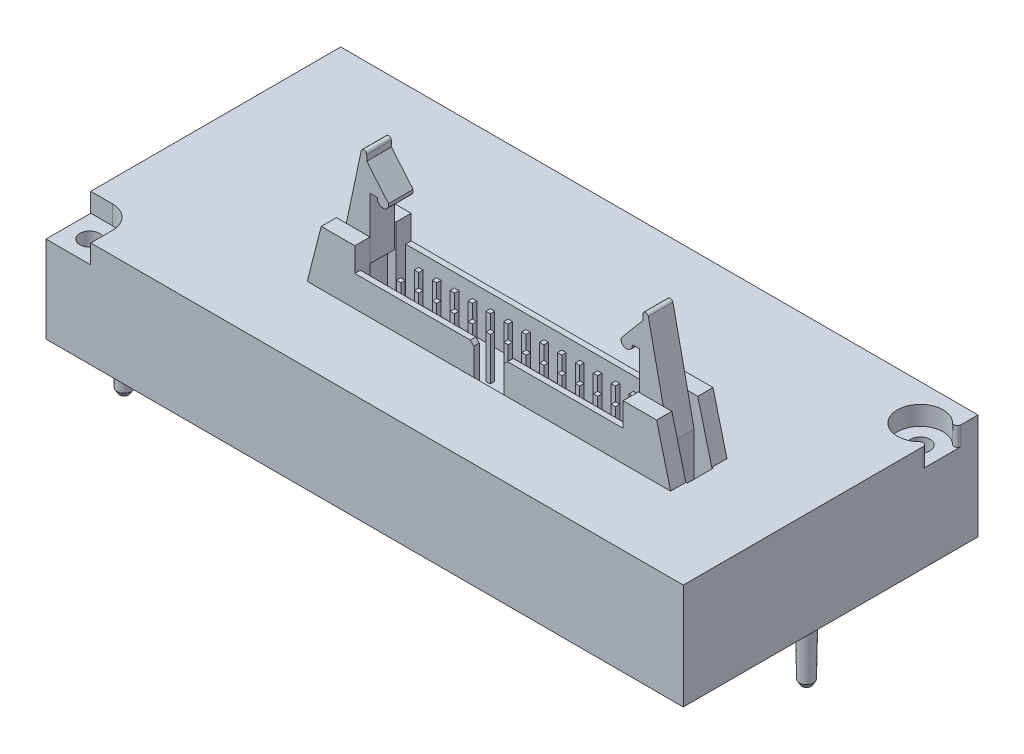
from build123d import *

# Parameters (mm, degrees)
SKETCH1_W                = 90.5
SKETCH1_H                = 41.85
SKETCH1_R                = 1.4
BOSS_EXTRUDE1_DEPTH      = 15
SKETCH2_W                = 105
SKETCH2_H                = 60
CUT_EXTRUDE1_DEPTH       = 2.7
BOSS_EXTRUDE2_DEPTH      = 4
BOSS_EXTRUDE2_DEPTH_BACK = 4
SKETCH7_W                = 38.1
SKETCH7_H                = 6.43
CUT_EXTRUDE2_DEPTH       = 6.4
CUT_EXTRUDE2_DEPTH_BACK  = 6.4
CUT_EXTRUDE3_DEPTH       = 1
SKETCH9_W                = 3.68
SKETCH9_H                = 13
CUT_EXTRUDE4_DEPTH       = 7
SKETCH10_W               = 3.68
SKETCH10_H               = 13
CUT_EXTRUDE5_DEPTH       = 7
SKETCH11_R               = 0.5
BOSS_EXTRUDE3_DEPTH      = 3
BOSS_EXTRUDE3_DEPTH_BACK = 3
SKETCH12_R               = 0.5
BOSS_EXTRUDE4_DEPTH      = 3
BOSS_EXTRUDE4_DEPTH_BACK = 3
BOSS_EXTRUDE5_DEPTH      = 1.75
BOSS_EXTRUDE5_DEPTH_BACK = 1.75
BOSS_EXTRUDE6_DEPTH      = 1.75
BOSS_EXTRUDE6_DEPTH_BACK = 1.75
SKETCH15_W               = 0.62
SKETCH15_H               = 0.62
BOSS_EXTRUDE7_DEPTH      = 6.1
SKETCH16_W               = 0.62
SKETCH16_H               = 0.62
BOSS_EXTRUDE8_DEPTH      = 6.1
SKETCH17_W               = 0.62
SKETCH17_H               = 0.62
BOSS_EXTRUDE9_DEPTH      = 6.1
SKETCH18_W               = 0.62
SKETCH18_H               = 0.62
BOSS_EXTRUDE10_DEPTH     = 6.1
SKETCH19_W               = 0.62
SKETCH19_H               = 0.62
BOSS_EXTRUDE11_DEPTH     = 6.1
SKETCH20_W               = 0.62
SKETCH20_H               = 0.62
BOSS_EXTRUDE12_DEPTH     = 6.1
SKETCH21_W               = 0.62
SKETCH21_H               = 0.62
BOSS_EXTRUDE13_DEPTH     = 6.1
SKETCH22_W               = 0.62
SKETCH22_H               = 0.62
BOSS_EXTRUDE14_DEPTH     = 6.1
SKETCH23_W               = 0.62
SKETCH23_H               = 0.62
BOSS_EXTRUDE15_DEPTH     = 6.1
SKETCH24_W               = 0.62
SKETCH24_H               = 0.62
BOSS_EXTRUDE16_DEPTH     = 6.1
SKETCH25_W               = 0.62
SKETCH25_H               = 0.62
BOSS_EXTRUDE17_DEPTH     = 6.1
SKETCH26_W               = 0.62
SKETCH26_H               = 0.62
BOSS_EXTRUDE18_DEPTH     = 6.1
SKETCH27_W               = 0.62
SKETCH27_H               = 0.62
BOSS_EXTRUDE19_DEPTH     = 6.1
SKETCH28_W               = 0.62
SKETCH28_H               = 0.62
BOSS_EXTRUDE20_DEPTH     = 6.1
SKETCH29_W               = 0.62
SKETCH29_H               = 0.62
BOSS_EXTRUDE21_DEPTH     = 6.1
SKETCH30_W               = 0.62
SKETCH30_H               = 0.62
BOSS_EXTRUDE22_DEPTH     = 6.1
SKETCH31_W               = 0.62
SKETCH31_H               = 0.62
BOSS_EXTRUDE23_DEPTH     = 6.1
SKETCH32_W               = 0.62
SKETCH32_H               = 0.62
BOSS_EXTRUDE24_DEPTH     = 6.1
SKETCH33_W               = 0.62
SKETCH33_H               = 0.62
BOSS_EXTRUDE25_DEPTH     = 6.1
SKETCH34_W               = 0.62
SKETCH34_H               = 0.62
BOSS_EXTRUDE26_DEPTH     = 6.1
SKETCH35_W               = 0.62
SKETCH35_H               = 0.62
BOSS_EXTRUDE27_DEPTH     = 6.1
SKETCH36_W               = 0.62
SKETCH36_H               = 0.62
BOSS_EXTRUDE28_DEPTH     = 6.1
SKETCH37_W               = 0.62
SKETCH37_H               = 0.62
BOSS_EXTRUDE29_DEPTH     = 6.1
SKETCH38_W               = 0.62
SKETCH38_H               = 0.62
BOSS_EXTRUDE30_DEPTH     = 6.1
SKETCH39_W               = 0.62
SKETCH39_H               = 0.62
BOSS_EXTRUDE31_DEPTH     = 6.1
SKETCH40_W               = 0.62
SKETCH40_H               = 0.62
BOSS_EXTRUDE32_DEPTH     = 6.1


with BuildPart() as part:
    # Sketch1 → Boss-Extrude1 (new body)
    with BuildSketch(Plane(origin=(0, 0, 0), x_dir=(1, 0, 0), z_dir=(0, 1, 0))):
        with Locations((11, -5.675)):
            Rectangle(SKETCH1_W, SKETCH1_H)
        with Locations((53.15, 10.15)):
            Circle(SKETCH1_R, mode=Mode.SUBTRACT)
        with Locations((-31.15, -23.5)):
            Circle(SKETCH1_R, mode=Mode.SUBTRACT)
    extrude(amount=BOSS_EXTRUDE1_DEPTH)

    # Sketch2 → Cut-Extrude1 (cut)
    with BuildSketch(Plane(origin=(0, 15, 0), x_dir=(1, 0, 0), z_dir=(0, 1, 0))):
        with Locations((12.5, -5)):
            Rectangle(SKETCH2_W, SKETCH2_H)
        with BuildLine():
            Line((-34.25, 15.25), (-34.25, -20.25))
            Line((-34.25, -20.25), (-31.15, -20.25))
            ThreePointArc((-31.15, -20.25), (-28.851902961, -21.201902961), (-27.9, -23.5))
            Line((-27.9, -23.5), (-27.9, -26.6))
            Line((-27.9, -26.6), (56.25, -26.6))
            Line((56.25, -26.6), (56.25, 7.447686177))
            ThreePointArc((56.25, 7.447686177), (55.945788972, 7.907758648), (55.403333286, 7.807994641))
            ThreePointArc((55.403333286, 7.807994641), (49.9, 10.150000033), (55.403333333, 12.492005314))
            ThreePointArc((55.403333333, 12.492005314), (55.945789002, 12.392241365), (56.25, 12.852313823))
            Line((56.25, 12.852313823), (56.25, 15.25))
            Line((56.25, 15.25), (-34.25, 15.25))
        make_face(mode=Mode.SUBTRACT)
    extrude(amount=-CUT_EXTRUDE1_DEPTH, mode=Mode.SUBTRACT)

    # Sketch3 → Revolve1 (revolve)
    with BuildSketch(Plane.XY.offset(6)):
        Polygon((53.15, 0), (54.3, 0), (54.15, -8.4), (53.8, -9), (53.15, -9), align=None)
    revolve(axis=Axis((53.15, -9, 6), (0, 1, 0)))

    # Sketch4 → Revolve2 (revolve)
    with BuildSketch(Plane.XY.offset(-5.25)):
        Polygon((-31.15, 0), (-30, 0), (-30.15, -8.4), (-30.5, -9), (-31.15, -9), align=None)
    revolve(axis=Axis((-31.15, -9, -5.25), (0, 1, 0)))

    # Sketch5 → Revolve3 (revolve)
    with BuildSketch(Plane.XY.offset(18.6)):
        Polygon((-31.15, 0), (-30, 0), (-30.15, -8.4), (-30.5, -9), (-31.15, -9), align=None)
    revolve(axis=Axis((-31.15, -9, 18.6), (0, 1, 0)))

    # Sketch6 → Boss-Extrude2 (add, two sides)
    with BuildSketch(Plane.XY.offset(11.95)) as boss_extrude2_sk:
        Polygon((-8.225, 13.35), (-8.225, 5.35), (44.225, 5.35), (44.225, 13.35), (41.815, 22.75), (37.05, 22.75), (37.05, 19.35), (-1.05, 19.35), (-1.05, 22.75), (-5.815, 22.75), align=None)
    extrude(amount=BOSS_EXTRUDE2_DEPTH)
    extrude(boss_extrude2_sk.sketch, amount=-BOSS_EXTRUDE2_DEPTH_BACK)

    # Sketch7 → Cut-Extrude2 (cut, two sides)
    with BuildSketch(Plane(origin=(0, 19.35, 0), x_dir=(1, 0, 0), z_dir=(0, 1, 0))) as cut_extrude2_sk:
        with Locations((18, -11.95)):
            Rectangle(SKETCH7_W, SKETCH7_H)
    extrude(amount=CUT_EXTRUDE2_DEPTH, mode=Mode.SUBTRACT)
    extrude(cut_extrude2_sk.sketch, amount=-CUT_EXTRUDE2_DEPTH_BACK, mode=Mode.SUBTRACT)

    # Sketch8 → Cut-Extrude3 (cut)
    with BuildSketch(Plane.XY.offset(15.95)):
        Polygon((15.35, 19.35), (15.85, 18.85), (15.85, 13.45), (16.35, 12.95), (19.65, 12.95), (20.15, 13.45), (20.15, 18.85), (20.65, 19.35), align=None)
    extrude(amount=-CUT_EXTRUDE3_DEPTH, mode=Mode.SUBTRACT)

    # Sketch9 → Cut-Extrude4 (cut)
    with BuildSketch(Plane(origin=(37, 0, 0), x_dir=(0, 0, -1), z_dir=(1, 0, 0))):
        with Locations((-11.95, 16.25)):
            Rectangle(SKETCH9_W, SKETCH9_H)
    extrude(amount=CUT_EXTRUDE4_DEPTH, mode=Mode.SUBTRACT)

    # Sketch10 → Cut-Extrude5 (cut)
    with BuildSketch(Plane(origin=(-1.05, 0, 0), x_dir=(0, 0, -1), z_dir=(1, 0, 0))):
        with Locations((-11.95, 16.25)):
            Rectangle(SKETCH10_W, SKETCH10_H)
    extrude(amount=-CUT_EXTRUDE5_DEPTH, mode=Mode.SUBTRACT)

    # Sketch11 → Boss-Extrude3 (add, two sides)
    with BuildSketch(Plane.XY.offset(11.95)) as boss_extrude3_sk:
        with Locations((40.225, 15.21)):
            Circle(SKETCH11_R)
    extrude(amount=BOSS_EXTRUDE3_DEPTH)
    extrude(boss_extrude3_sk.sketch, amount=-BOSS_EXTRUDE3_DEPTH_BACK)

    # Sketch12 → Boss-Extrude4 (add, two sides)
    with BuildSketch(Plane.XY.offset(11.95)) as boss_extrude4_sk:
        with Locations((-4.225, 15.21)):
            Circle(SKETCH12_R)
    extrude(amount=BOSS_EXTRUDE4_DEPTH)
    extrude(boss_extrude4_sk.sketch, amount=-BOSS_EXTRUDE4_DEPTH_BACK)

    # Sketch13 → Boss-Extrude5 (add, two sides)
    with BuildSketch(Plane.XY.offset(11.95)) as boss_extrude5_sk:
        with BuildLine():
            Line((36.100152425, 28.044506131), (37.155, 28.044506131))
            Line((37.155, 28.044506131), (37.155, 19.373))
            Line((37.155, 19.373), (38.155, 19.373))
            Line((38.155, 19.373), (38.155, 11.97026486))
            ThreePointArc((38.155, 11.97026486), (39.77, 11.15), (41.385, 11.97026486))
            Line((41.385, 11.97026486), (41.385, 18.512181097))
            Line((41.385, 18.512181097), (38.391302756, 32.632958744))
            ThreePointArc((38.391302756, 32.632958744), (37.9582933, 32.947819747), (37.6, 32.55))
            Line((37.6, 32.55), (37.6, 31.75))
            Line((37.6, 31.75), (34.514619474, 28.072986673))
            ThreePointArc((34.514619474, 28.072986673), (35.29056123, 27.122101776), (36.100152425, 28.044506131))
        make_face()
    extrude(amount=BOSS_EXTRUDE5_DEPTH)
    extrude(boss_extrude5_sk.sketch, amount=-BOSS_EXTRUDE5_DEPTH_BACK)

    # Sketch14 → Boss-Extrude6 (add, two sides)
    with BuildSketch(Plane.XY.offset(11.95)) as boss_extrude6_sk:
        with BuildLine():
            Line((-5.385, 18.512181097), (-5.385, 11.97026486))
            ThreePointArc((-5.385, 11.97026486), (-3.77, 11.15), (-2.155, 11.97026486))
            Line((-2.155, 11.97026486), (-2.155, 19.373))
            Line((-2.155, 19.373), (-1.155, 19.373))
            Line((-1.155, 19.373), (-1.155, 28.044506131))
            Line((-1.155, 28.044506131), (-0.100152425, 28.044506131))
            ThreePointArc((-0.100152425, 28.044506131), (0.70943877, 27.122101776), (1.485380526, 28.072986673))
            Line((1.485380526, 28.072986673), (-1.6, 31.75))
            Line((-1.6, 31.75), (-1.6, 32.55))
            ThreePointArc((-1.6, 32.55), (-1.9582933, 32.947819747), (-2.391302756, 32.632958744))
            Line((-2.391302756, 32.632958744), (-5.385, 18.512181097))
        make_face()
    extrude(amount=BOSS_EXTRUDE6_DEPTH)
    extrude(boss_extrude6_sk.sketch, amount=-BOSS_EXTRUDE6_DEPTH_BACK)

    # Sketch15 → Boss-Extrude7 (add)
    with BuildSketch(Plane(origin=(0, 12.95, 0), x_dir=(1, 0, 0), z_dir=(0, 1, 0))):
        with Locations((2.76, -13.22)):
            Rectangle(SKETCH15_W, SKETCH15_H)
    extrude(amount=BOSS_EXTRUDE7_DEPTH)

    # Sketch16 → Boss-Extrude8 (add)
    with BuildSketch(Plane(origin=(0, 12.95, 0), x_dir=(1, 0, 0), z_dir=(0, 1, 0))):
        with Locations((5.3, -13.22)):
            Rectangle(SKETCH16_W, SKETCH16_H)
    extrude(amount=BOSS_EXTRUDE8_DEPTH)

    # Sketch17 → Boss-Extrude9 (add)
    with BuildSketch(Plane(origin=(0, 12.95, 0), x_dir=(1, 0, 0), z_dir=(0, 1, 0))):
        with Locations((7.84, -13.22)):
            Rectangle(SKETCH17_W, SKETCH17_H)
    extrude(amount=BOSS_EXTRUDE9_DEPTH)

    # Sketch18 → Boss-Extrude10 (add)
    with BuildSketch(Plane(origin=(0, 12.95, 0), x_dir=(1, 0, 0), z_dir=(0, 1, 0))):
        with Locations((10.38, -13.22)):
            Rectangle(SKETCH18_W, SKETCH18_H)
    extrude(amount=BOSS_EXTRUDE10_DEPTH)

    # Sketch19 → Boss-Extrude11 (add)
    with BuildSketch(Plane(origin=(0, 12.95, 0), x_dir=(1, 0, 0), z_dir=(0, 1, 0))):
        with Locations((12.92, -13.22)):
            Rectangle(SKETCH19_W, SKETCH19_H)
    extrude(amount=BOSS_EXTRUDE11_DEPTH)

    # Sketch20 → Boss-Extrude12 (add)
    with BuildSketch(Plane(origin=(0, 12.95, 0), x_dir=(1, 0, 0), z_dir=(0, 1, 0))):
        with Locations((15.46, -13.22)):
            Rectangle(SKETCH20_W, SKETCH20_H)
    extrude(amount=BOSS_EXTRUDE12_DEPTH)

    # Sketch21 → Boss-Extrude13 (add)
    with BuildSketch(Plane(origin=(0, 12.95, 0), x_dir=(1, 0, 0), z_dir=(0, 1, 0))):
        with Locations((18, -13.22)):
            Rectangle(SKETCH21_W, SKETCH21_H)
    extrude(amount=BOSS_EXTRUDE13_DEPTH)

    # Sketch22 → Boss-Extrude14 (add)
    with BuildSketch(Plane(origin=(0, 12.95, 0), x_dir=(1, 0, 0), z_dir=(0, 1, 0))):
        with Locations((20.54, -13.22)):
            Rectangle(SKETCH22_W, SKETCH22_H)
    extrude(amount=BOSS_EXTRUDE14_DEPTH)

    # Sketch23 → Boss-Extrude15 (add)
    with BuildSketch(Plane(origin=(0, 12.95, 0), x_dir=(1, 0, 0), z_dir=(0, 1, 0))):
        with Locations((23.08, -13.22)):
            Rectangle(SKETCH23_W, SKETCH23_H)
    extrude(amount=BOSS_EXTRUDE15_DEPTH)

    # Sketch24 → Boss-Extrude16 (add)
    with BuildSketch(Plane(origin=(0, 12.95, 0), x_dir=(1, 0, 0), z_dir=(0, 1, 0))):
        with Locations((25.62, -13.22)):
            Rectangle(SKETCH24_W, SKETCH24_H)
    extrude(amount=BOSS_EXTRUDE16_DEPTH)

    # Sketch25 → Boss-Extrude17 (add)
    with BuildSketch(Plane(origin=(0, 12.95, 0), x_dir=(1, 0, 0), z_dir=(0, 1, 0))):
        with Locations((28.16, -13.22)):
            Rectangle(SKETCH25_W, SKETCH25_H)
    extrude(amount=BOSS_EXTRUDE17_DEPTH)

    # Sketch26 → Boss-Extrude18 (add)
    with BuildSketch(Plane(origin=(0, 12.95, 0), x_dir=(1, 0, 0), z_dir=(0, 1, 0))):
        with Locations((30.7, -13.22)):
            Rectangle(SKETCH26_W, SKETCH26_H)
    extrude(amount=BOSS_EXTRUDE18_DEPTH)

    # Sketch27 → Boss-Extrude19 (add)
    with BuildSketch(Plane(origin=(0, 12.95, 0), x_dir=(1, 0, 0), z_dir=(0, 1, 0))):
        with Locations((33.24, -13.22)):
            Rectangle(SKETCH27_W, SKETCH27_H)
    extrude(amount=BOSS_EXTRUDE19_DEPTH)

    # Sketch28 → Boss-Extrude20 (add)
    with BuildSketch(Plane(origin=(0, 12.95, 0), x_dir=(1, 0, 0), z_dir=(0, 1, 0))):
        with Locations((2.76, -10.68)):
            Rectangle(SKETCH28_W, SKETCH28_H)
    extrude(amount=BOSS_EXTRUDE20_DEPTH)

    # Sketch29 → Boss-Extrude21 (add)
    with BuildSketch(Plane(origin=(0, 12.95, 0), x_dir=(1, 0, 0), z_dir=(0, 1, 0))):
        with Locations((5.3, -10.68)):
            Rectangle(SKETCH29_W, SKETCH29_H)
    extrude(amount=BOSS_EXTRUDE21_DEPTH)

    # Sketch30 → Boss-Extrude22 (add)
    with BuildSketch(Plane(origin=(0, 12.95, 0), x_dir=(1, 0, 0), z_dir=(0, 1, 0))):
        with Locations((7.84, -10.68)):
            Rectangle(SKETCH30_W, SKETCH30_H)
    extrude(amount=BOSS_EXTRUDE22_DEPTH)

    # Sketch31 → Boss-Extrude23 (add)
    with BuildSketch(Plane(origin=(0, 12.95, 0), x_dir=(1, 0, 0), z_dir=(0, 1, 0))):
        with Locations((10.38, -10.68)):
            Rectangle(SKETCH31_W, SKETCH31_H)
    extrude(amount=BOSS_EXTRUDE23_DEPTH)

    # Sketch32 → Boss-Extrude24 (add)
    with BuildSketch(Plane(origin=(0, 12.95, 0), x_dir=(1, 0, 0), z_dir=(0, 1, 0))):
        with Locations((12.92, -10.68)):
            Rectangle(SKETCH32_W, SKETCH32_H)
    extrude(amount=BOSS_EXTRUDE24_DEPTH)

    # Sketch33 → Boss-Extrude25 (add)
    with BuildSketch(Plane(origin=(0, 12.95, 0), x_dir=(1, 0, 0), z_dir=(0, 1, 0))):
        with Locations((15.46, -10.68)):
            Rectangle(SKETCH33_W, SKETCH33_H)
    extrude(amount=BOSS_EXTRUDE25_DEPTH)

    # Sketch34 → Boss-Extrude26 (add)
    with BuildSketch(Plane(origin=(0, 12.95, 0), x_dir=(1, 0, 0), z_dir=(0, 1, 0))):
        with Locations((18, -10.68)):
            Rectangle(SKETCH34_W, SKETCH34_H)
    extrude(amount=BOSS_EXTRUDE26_DEPTH)

    # Sketch35 → Boss-Extrude27 (add)
    with BuildSketch(Plane(origin=(0, 12.95, 0), x_dir=(1, 0, 0), z_dir=(0, 1, 0))):
        with Locations((20.54, -10.68)):
            Rectangle(SKETCH35_W, SKETCH35_H)
    extrude(amount=BOSS_EXTRUDE27_DEPTH)

    # Sketch36 → Boss-Extrude28 (add)
    with BuildSketch(Plane(origin=(0, 12.95, 0), x_dir=(1, 0, 0), z_dir=(0, 1, 0))):
        with Locations((23.08, -10.68)):
            Rectangle(SKETCH36_W, SKETCH36_H)
    extrude(amount=BOSS_EXTRUDE28_DEPTH)

    # Sketch37 → Boss-Extrude29 (add)
    with BuildSketch(Plane(origin=(0, 12.95, 0), x_dir=(1, 0, 0), z_dir=(0, 1, 0))):
        with Locations((25.62, -10.68)):
            Rectangle(SKETCH37_W, SKETCH37_H)
    extrude(amount=BOSS_EXTRUDE29_DEPTH)

    # Sketch38 → Boss-Extrude30 (add)
    with BuildSketch(Plane(origin=(0, 12.95, 0), x_dir=(1, 0, 0), z_dir=(0, 1, 0))):
        with Locations((28.16, -10.68)):
            Rectangle(SKETCH38_W, SKETCH38_H)
    extrude(amount=BOSS_EXTRUDE30_DEPTH)

    # Sketch39 → Boss-Extrude31 (add)
    with BuildSketch(Plane(origin=(0, 12.95, 0), x_dir=(1, 0, 0), z_dir=(0, 1, 0))):
        with Locations((30.7, -10.68)):
            Rectangle(SKETCH39_W, SKETCH39_H)
    extrude(amount=BOSS_EXTRUDE31_DEPTH)

    # Sketch40 → Boss-Extrude32 (add)
    with BuildSketch(Plane(origin=(0, 12.95, 0), x_dir=(1, 0, 0), z_dir=(0, 1, 0))):
        with Locations((33.24, -10.68)):
            Rectangle(SKETCH40_W, SKETCH40_H)
    extrude(amount=BOSS_EXTRUDE32_DEPTH)


solid = part.part
